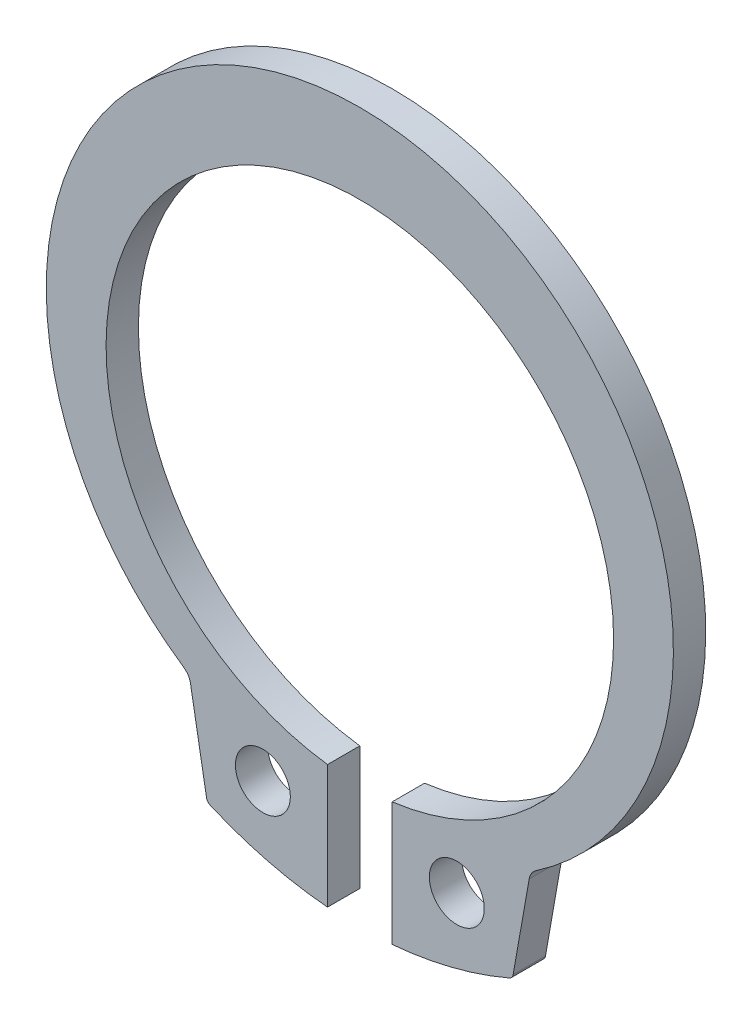
from build123d import *

# Parameters (mm, degrees)
SKETCH1_R  = 0.85
BODY_DEPTH = 1
FILLET1_R  = 0.2
FILLET2_R  = 0.5


with BuildPart() as part:
    # Sketch1 → Body (new body)
    with BuildSketch(Plane.XY):
        with BuildLine():
            Line((-1, -8.406045209), (-1, -12.227002197))
            ThreePointArc((-1, -12.227002197), (-2.901836737, -11.902811864), (-4.724092893, -11.269199328))
            Line((-4.724092893, -11.269199328), (-5.275907107, -8.139705412))
            ThreePointArc((-5.275907107, -8.139705412), (0, 9.7), (5.275907107, -8.139705412))
            Line((5.275907107, -8.139705412), (4.724092893, -11.269199328))
            ThreePointArc((4.724092893, -11.269199328), (2.901836737, -11.902811864), (1, -12.227002197))
            Line((1, -12.227002197), (1, -8.406045209))
            ThreePointArc((1, -8.406045209), (0, 7.23), (-1, -8.406045209))
        make_face()
        with Locations((3, -9.844424101)):
            Circle(SKETCH1_R, mode=Mode.SUBTRACT)
        with Locations((-3, -9.844424101)):
            Circle(SKETCH1_R, mode=Mode.SUBTRACT)
    extrude(amount=-BODY_DEPTH)

    # Fillet1
    fillet1_edges = [part.edges().sort_by_distance(p)[0] for p in [
        (-4.724092893, -11.269199328, -0.5),
        (4.724092893, -11.269199328, -0.5),
    ]]
    fillet(fillet1_edges, radius=FILLET1_R)

    # Fillet2
    fillet2_edges = [part.edges().sort_by_distance(p)[0] for p in [
        (-5.275907107, -8.139705412, -0.5),
        (5.275907107, -8.139705412, -0.5),
    ]]
    fillet(fillet2_edges, radius=FILLET2_R)


solid = part.part
